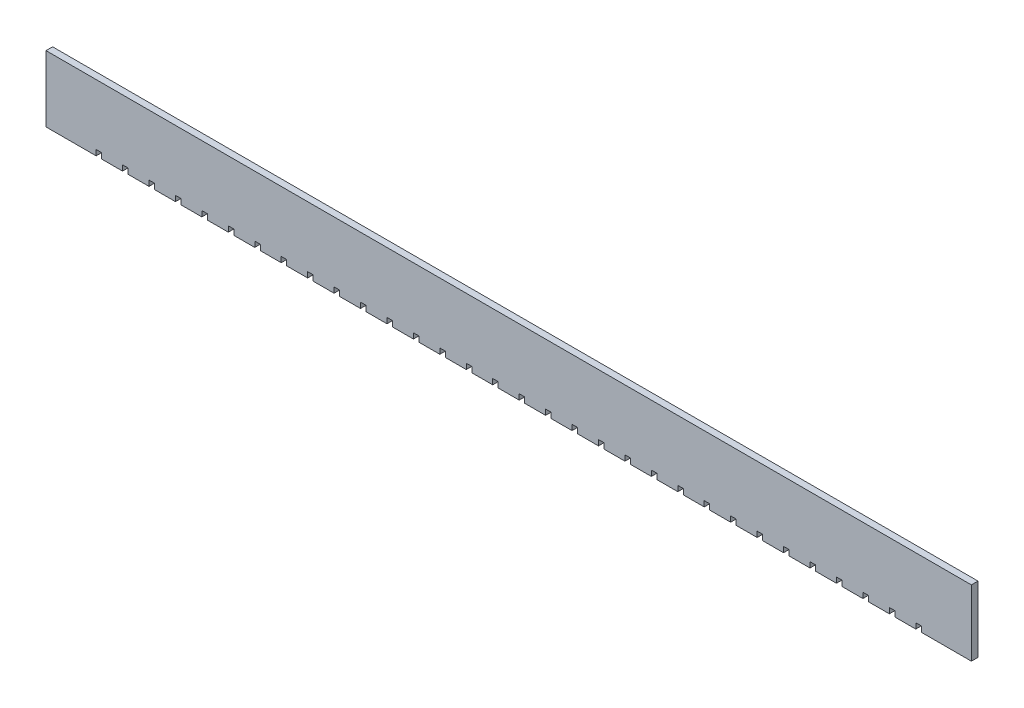
from build123d import *

# Parameters (mm, degrees)
BOSS_EXTRUDE1_DEPTH = 1.5


with BuildPart() as part:
    # Sketch1 → Boss-Extrude1 (new body)
    with BuildSketch(Plane.XY):
        Polygon((0, 0), (0, 15), (210, 15), (210, 0), (198.625, 0), (198.625, 1.25), (197.375, 1.25), (197.375, 0), (192.625, 0), (192.625, 1.25), (191.375, 1.25), (191.375, 0), (186.625, 0), (186.625, 1.25), (185.375, 1.25), (185.375, 0), (180.625, 0), (180.625, 1.25), (179.375, 1.25), (179.375, 0), (174.625, 0), (174.625, 1.25), (173.375, 1.25), (173.375, 0), (168.625, 0), (168.625, 1.25), (167.375, 1.25), (167.375, 0), (162.625, 0), (162.625, 1.25), (161.375, 1.25), (161.375, 0), (156.625, 0), (156.625, 1.25), (155.375, 1.25), (155.375, 0), (150.625, 0), (150.625, 1.25), (149.375, 1.25), (149.375, 0), (144.625, 0), (144.625, 1.25), (143.375, 1.25), (143.375, 0), (138.625, 0), (138.625, 1.25), (137.375, 1.25), (137.375, 0), (132.625, 0), (132.625, 1.25), (131.375, 1.25), (131.375, 0), (126.625, 0), (126.625, 1.25), (125.375, 1.25), (125.375, 0), (120.625, 0), (120.625, 1.25), (119.375, 1.25), (119.375, 0), (114.625, 0), (114.625, 1.25), (113.375, 1.25), (113.375, 0), (108.625, 0), (108.625, 1.25), (107.375, 1.25), (107.375, 0), (102.625, 0), (102.625, 1.25), (101.375, 1.25), (101.375, 0), (96.625, 0), (96.625, 1.25), (95.375, 1.25), (95.375, 0), (90.625, 0), (90.625, 1.25), (89.375, 1.25), (89.375, 0), (84.625, 0), (84.625, 1.25), (83.375, 1.25), (83.375, 0), (78.625, 0), (78.625, 1.25), (77.375, 1.25), (77.375, 0), (72.625, 0), (72.625, 1.25), (71.375, 1.25), (71.375, 0), (66.625, 0), (66.625, 1.25), (65.375, 1.25), (65.375, 0), (60.625, 0), (60.625, 1.25), (59.375, 1.25), (59.375, 0), (54.625, 0), (54.625, 1.25), (53.375, 1.25), (53.375, 0), (48.625, 0), (48.625, 1.25), (47.375, 1.25), (47.375, 0), (42.625, 0), (42.625, 1.25), (41.375, 1.25), (41.375, 0), (36.625, 0), (36.625, 1.25), (35.375, 1.25), (35.375, 0), (30.625, 0), (30.625, 1.25), (29.375, 1.25), (29.375, 0), (24.625, 0), (24.625, 1.25), (23.375, 1.25), (23.375, 0), (18.625, 0), (18.625, 1.25), (17.375, 1.25), (17.375, 0), (12.625, 0), (12.625, 1.25), (11.375, 1.25), (11.375, 0), align=None)
    extrude(amount=BOSS_EXTRUDE1_DEPTH)


solid = part.part
